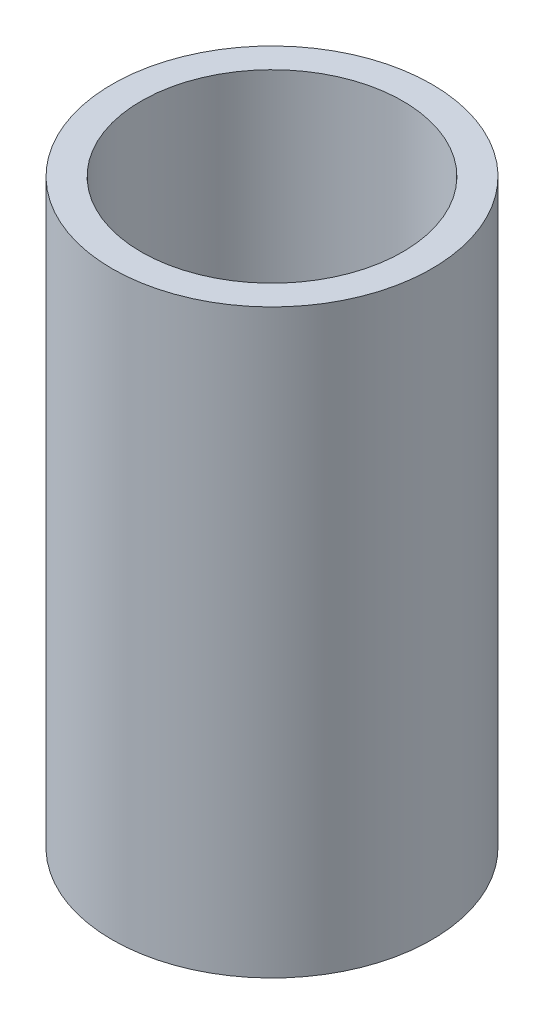
from build123d import *

# Parameters (mm, degrees)
SKETCH1_R           = 2.75
SKETCH1_R_2         = 2.25
BOSS_EXTRUDE1_DEPTH = 10


with BuildPart() as part:
    # Sketch1 → Boss-Extrude1 (new body)
    with BuildSketch(Plane(origin=(0, 0, 0), x_dir=(1, 0, 0), z_dir=(0, 1, 0))):
        Circle(SKETCH1_R)
        Circle(SKETCH1_R_2, mode=Mode.SUBTRACT)
    extrude(amount=BOSS_EXTRUDE1_DEPTH)


solid = part.part
